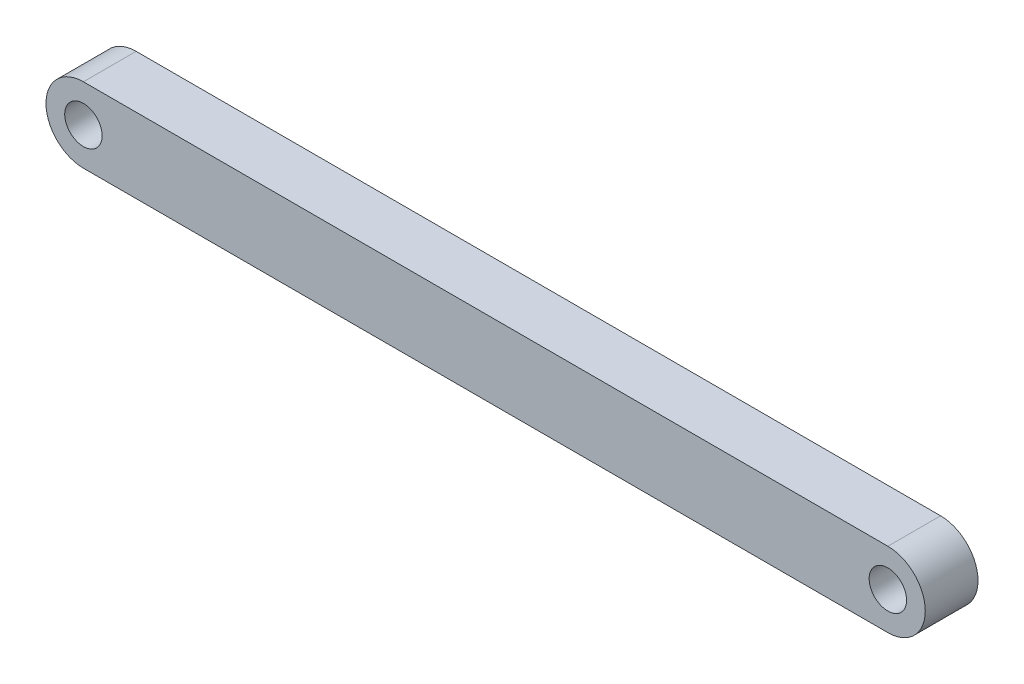
from build123d import *

# Parameters (mm, degrees)
SKETCH1_R           = 0.8875
BOSS_EXTRUDE1_DEPTH = 2.5


with BuildPart() as part:
    # Sketch1 → Boss-Extrude1 (new body)
    with BuildSketch(Plane.XY):
        with BuildLine():
            Line((-38.15, 1.775), (0, 1.775))
            ThreePointArc((0, 1.775), (1.775, 0), (0, -1.775))
            Line((0, -1.775), (-38.15, -1.775))
            ThreePointArc((-38.15, -1.775), (-39.925, 0), (-38.15, 1.775))
        make_face()
        Circle(SKETCH1_R, mode=Mode.SUBTRACT)
        with Locations((-38.15, 0)):
            Circle(SKETCH1_R, mode=Mode.SUBTRACT)
    extrude(amount=BOSS_EXTRUDE1_DEPTH)


solid = part.part
